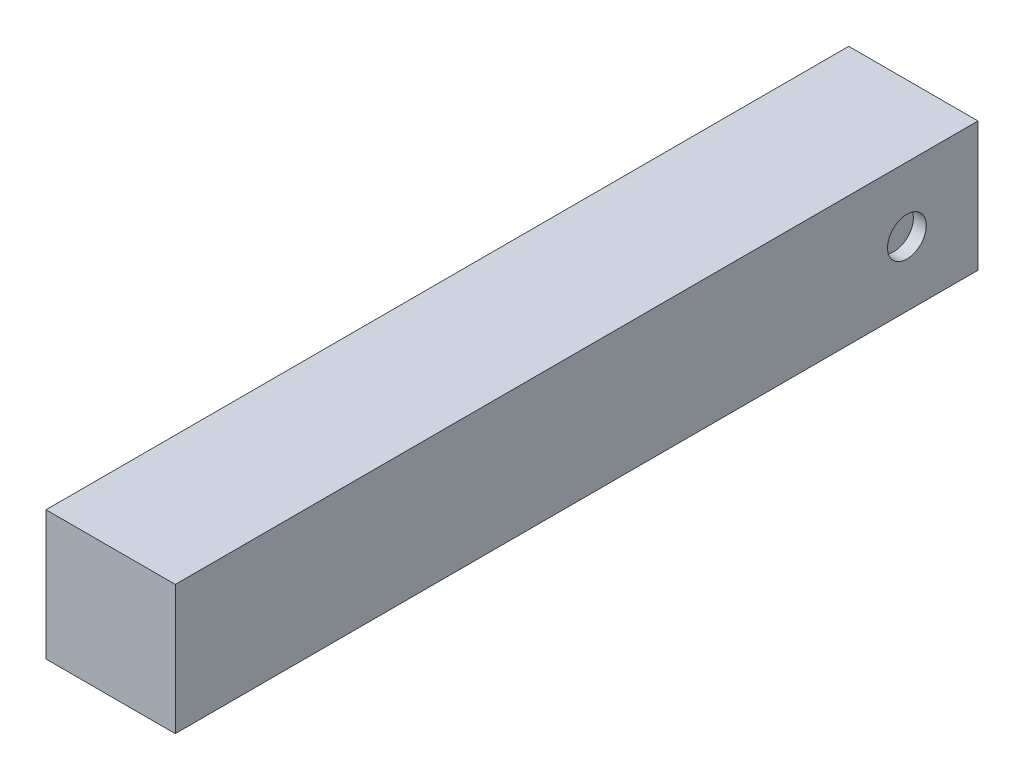
from build123d import *

# Parameters (mm, degrees)
EXTRUDE_1_DEPTH     = 20
SKETCH_2_R          = 6
CUT_EXTRUDE_1_DEPTH = 80
SKETCH_3_R          = 3
CUT_EXTRUDE_2_DEPTH = 2


with BuildPart() as part:
    # 草图1 → 凸台-拉伸1 (new body)
    with BuildSketch(Plane(origin=(0, 0, 0), x_dir=(0, 0, -1), z_dir=(1, 0, 0))):
        Polygon((-14.17593604, 10), (-14.175953417, -10), (110, -10), (110, 10), align=None)
    extrude(amount=EXTRUDE_1_DEPTH)

    # 草图2 → 切除-拉伸1 (cut)
    with BuildSketch(Plane(origin=(0, 0, -110), x_dir=(-1, 0, 0), z_dir=(0, 0, -1))):
        with Locations((-10, 0)):
            Circle(SKETCH_2_R)
    extrude(amount=-CUT_EXTRUDE_1_DEPTH, mode=Mode.SUBTRACT)

    # 草图3 → 切除-拉伸2 (cut)
    with BuildSketch(Plane(origin=(20, 0, 0), x_dir=(0, 0, -1), z_dir=(1, 0, 0))):
        with Locations((99, 0)):
            Circle(SKETCH_3_R)
    extrude(amount=-CUT_EXTRUDE_2_DEPTH, mode=Mode.SUBTRACT)


solid = part.part
